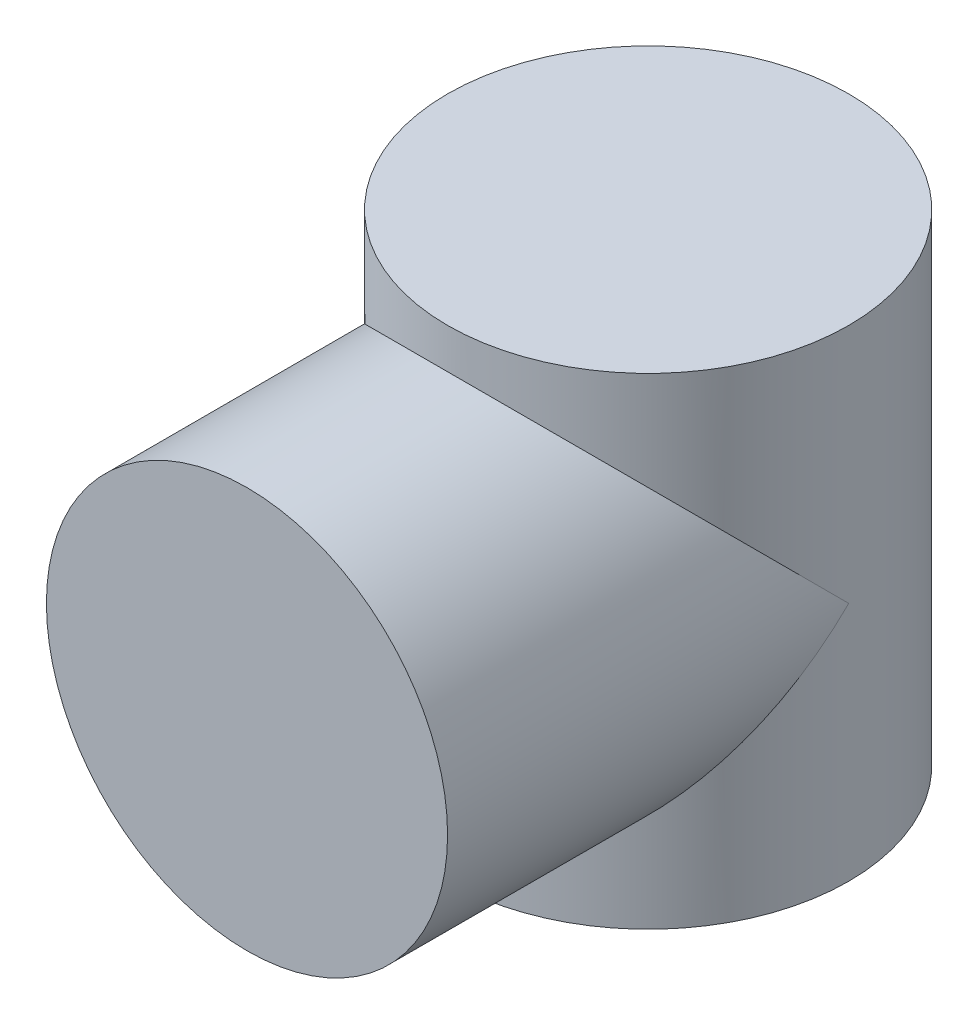
from build123d import *

# Parameters (mm, degrees)
SKETCH_1_R      = 50
EXTRUDE_1_DEPTH = 60
SKETCH_3_R      = 50
EXTRUDE_2_DEPTH = 100


with BuildPart() as part:
    # 草图1 → 凸台-拉伸1 (new body, symmetric)
    with BuildSketch(Plane(origin=(0, 0, 0), x_dir=(1, 0, 0), z_dir=(0, 1, 0))):
        Circle(SKETCH_1_R)
    extrude(amount=EXTRUDE_1_DEPTH, both=True)

    # 草图3 → 凸台-拉伸2 (add)
    with BuildSketch(Plane.XY):
        Circle(SKETCH_3_R)
    extrude(amount=EXTRUDE_2_DEPTH)


solid = part.part
